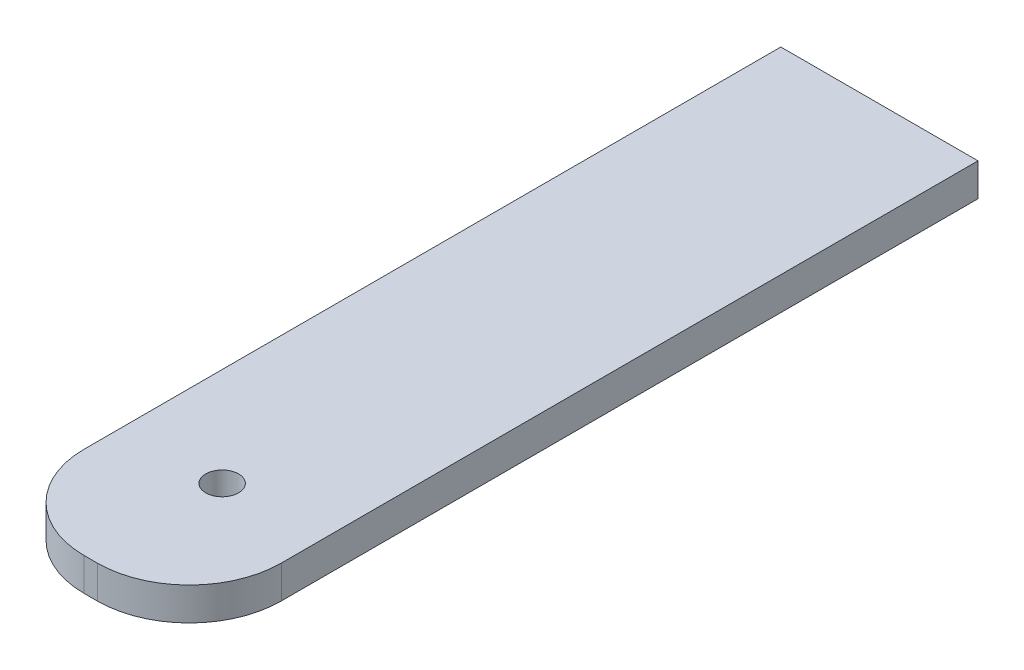
from build123d import *

# Parameters (mm, degrees)
SKETCH2_W           = 19.05
SKETCH2_H           = 76.2
SKETCH2_R           = 1.5875
BOSS_EXTRUDE1_DEPTH = 3.175
FILLET1_R           = 8.89
FILLET2_R           = 8.89


with BuildPart() as part:
    # Sketch2 → Boss-Extrude1 (new body)
    with BuildSketch(Plane(origin=(0, 0, 0), x_dir=(1, 0, 0), z_dir=(0, 1, 0))):
        Rectangle(SKETCH2_W, SKETCH2_H)
        with Locations((0, -25.4)):
            Circle(SKETCH2_R, mode=Mode.SUBTRACT)
    extrude(amount=BOSS_EXTRUDE1_DEPTH)

    # Fillet1
    fillet1_edges = [part.edges().sort_by_distance(p)[0] for p in [
        (9.525, 1.5875, 38.1),
    ]]
    fillet(fillet1_edges, radius=FILLET1_R)

    # Fillet2
    fillet2_edges = [part.edges().sort_by_distance(p)[0] for p in [
        (-9.525, 1.5875, 38.1),
    ]]
    fillet(fillet2_edges, radius=FILLET2_R)


solid = part.part
